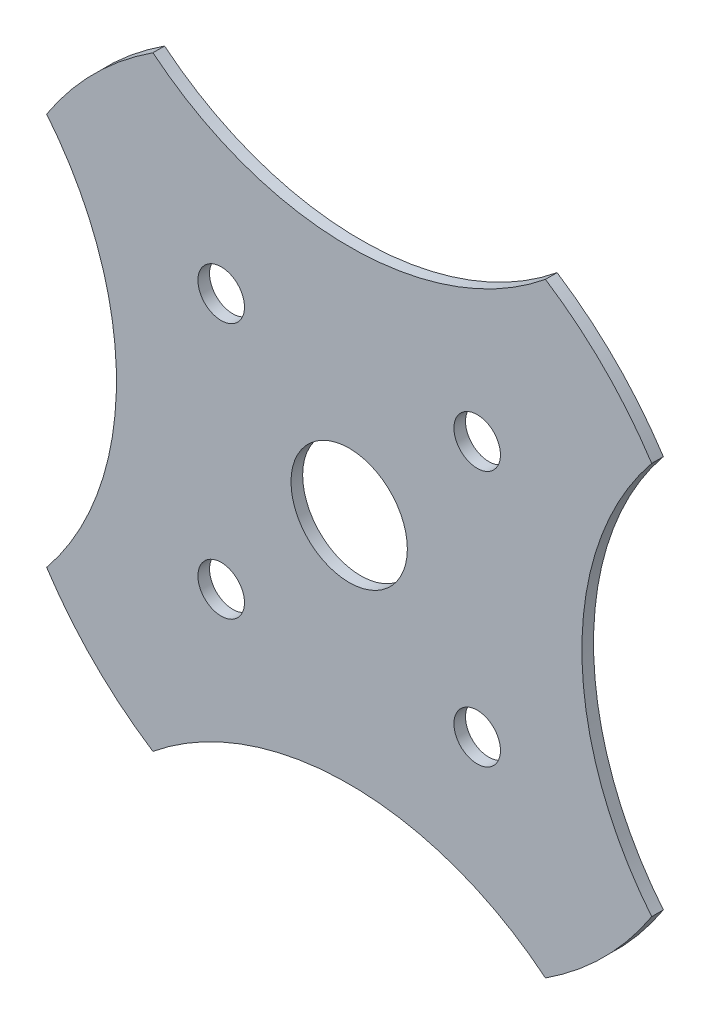
from build123d import *

# Parameters (mm, degrees)
EXTRUDE1_DEPTH     = 3.175
CUT_EXTRUDE1_REACH = 5.175
SKETCH2_R          = 6.35
SKETCH2_R_2        = 15.875


with BuildPart() as part:
    # Sketch1 → Extrude1 (new body)
    with BuildSketch(Plane.XY):
        with BuildLine():
            ThreePointArc((-53.553513238, 82.55), (0, 63.5), (53.553513238, 82.55))
            ThreePointArc((53.553513238, 82.55), (69.579024426, 69.579024426), (82.55, 53.553513238))
            ThreePointArc((82.55, 53.553513238), (63.5, 0), (82.55, -53.553513238))
            ThreePointArc((82.55, -53.553513238), (69.579024426, -69.579024426), (53.553513238, -82.55))
            ThreePointArc((53.553513238, -82.55), (0, -63.5), (-53.553513238, -82.55))
            ThreePointArc((-53.553513238, -82.55), (-69.579024426, -69.579024426), (-82.55, -53.553513238))
            ThreePointArc((-82.55, -53.553513238), (-63.5, 0), (-82.55, 53.553513238))
            ThreePointArc((-82.55, 53.553513238), (-69.579024426, 69.579024426), (-53.553513238, 82.55))
        make_face()
    extrude(amount=-EXTRUDE1_DEPTH)

    # Sketch2 → Cut-Extrude1 (cut, up to next)
    with BuildSketch(Plane(origin=(0, 0, -3.175), x_dir=(-1, 0, 0), z_dir=(0, 0, -1)), mode=Mode.PRIVATE) as cut_extrude1_sk1:
        with Locations((-34.925, 34.925)):
            Circle(SKETCH2_R)
    cut_extrude1_tool1 = extrude(cut_extrude1_sk1.sketch, amount=-CUT_EXTRUDE1_REACH, mode=Mode.PRIVATE) & part.part
    add(cut_extrude1_tool1.solids().sort_by_distance((34.925, 34.925, -3.175))[0], mode=Mode.SUBTRACT)
    # Sketch2 → Cut-Extrude1 (cut, up to next)
    with BuildSketch(Plane(origin=(0, 0, -3.175), x_dir=(-1, 0, 0), z_dir=(0, 0, -1)), mode=Mode.PRIVATE) as cut_extrude1_sk2:
        with Locations((34.925, 34.925)):
            Circle(SKETCH2_R)
    cut_extrude1_tool2 = extrude(cut_extrude1_sk2.sketch, amount=-CUT_EXTRUDE1_REACH, mode=Mode.PRIVATE) & part.part
    add(cut_extrude1_tool2.solids().sort_by_distance((-34.925, 34.925, -3.175))[0], mode=Mode.SUBTRACT)
    # Sketch2 → Cut-Extrude1 (cut, up to next)
    with BuildSketch(Plane(origin=(0, 0, -3.175), x_dir=(-1, 0, 0), z_dir=(0, 0, -1)), mode=Mode.PRIVATE) as cut_extrude1_sk3:
        with Locations((34.925, -34.925)):
            Circle(SKETCH2_R)
    cut_extrude1_tool3 = extrude(cut_extrude1_sk3.sketch, amount=-CUT_EXTRUDE1_REACH, mode=Mode.PRIVATE) & part.part
    add(cut_extrude1_tool3.solids().sort_by_distance((-34.925, -34.925, -3.175))[0], mode=Mode.SUBTRACT)
    # Sketch2 → Cut-Extrude1 (cut, up to next)
    with BuildSketch(Plane(origin=(0, 0, -3.175), x_dir=(-1, 0, 0), z_dir=(0, 0, -1)), mode=Mode.PRIVATE) as cut_extrude1_sk4:
        with Locations((-34.925, -34.925)):
            Circle(SKETCH2_R)
    cut_extrude1_tool4 = extrude(cut_extrude1_sk4.sketch, amount=-CUT_EXTRUDE1_REACH, mode=Mode.PRIVATE) & part.part
    add(cut_extrude1_tool4.solids().sort_by_distance((34.925, -34.925, -3.175))[0], mode=Mode.SUBTRACT)
    # Sketch2 → Cut-Extrude1 (cut, up to next)
    with BuildSketch(Plane(origin=(0, 0, -3.175), x_dir=(-1, 0, 0), z_dir=(0, 0, -1)), mode=Mode.PRIVATE) as cut_extrude1_sk5:
        Circle(SKETCH2_R_2)
    cut_extrude1_tool5 = extrude(cut_extrude1_sk5.sketch, amount=-CUT_EXTRUDE1_REACH, mode=Mode.PRIVATE) & part.part
    add(cut_extrude1_tool5.solids().sort_by_distance((0, 0, -3.175))[0], mode=Mode.SUBTRACT)


solid = part.part
